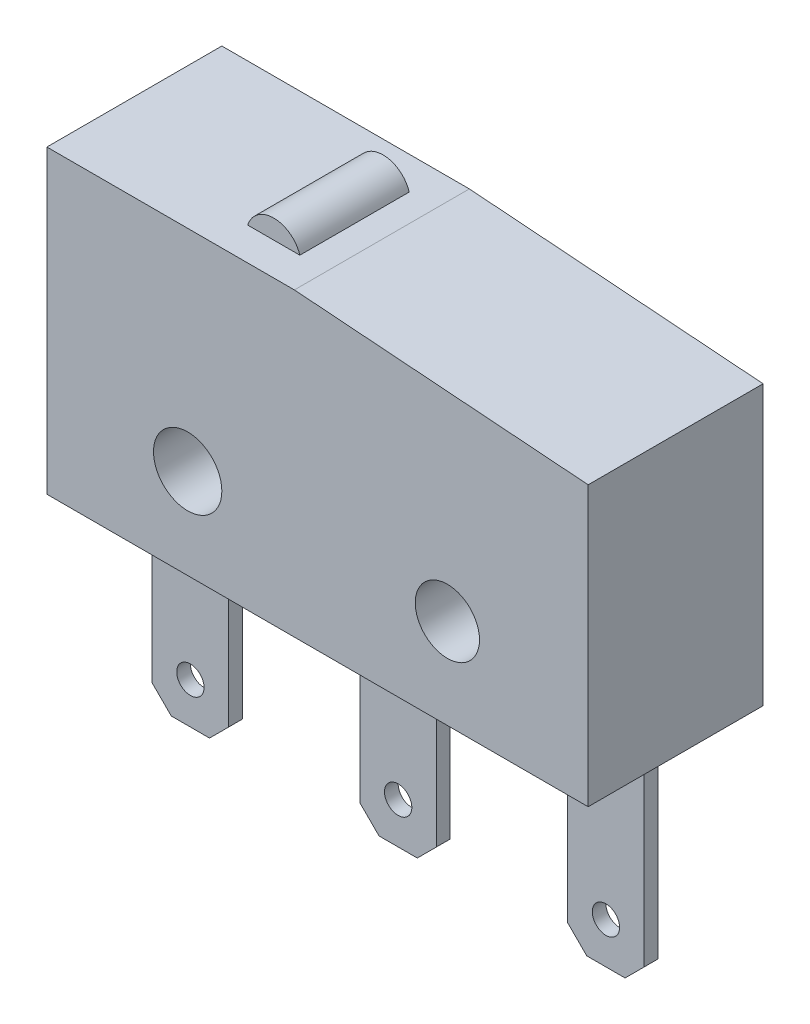
from build123d import *

# Parameters (mm, degrees)
SKETCH1_R           = 1.25
SKETCH1_R_2         = 1.175
BOSS_EXTRUDE1_DEPTH = 3.2
SKETCH2_R           = 0.5
BOSS_EXTRUDE2_DEPTH = 0.25
SKETCH3_W           = 2.907878402
SKETCH3_H           = 1.2
CUT_EXTRUDE1_DEPTH  = 1.7


with BuildPart() as part:
    # Sketch1 → Boss-Extrude1 (new body, symmetric)
    with BuildSketch(Plane.XY):
        with BuildLine():
            Line((-5.15, -3.3), (14.65, -3.3))
            Line((14.65, -3.3), (14.65, 6.9))
            Line((14.65, 6.9), (3.903939201, 7.7))
            Line((3.903939201, 7.7), (2.903939201, 7.7))
            ThreePointArc((2.903939201, 7.7), (1.95, 8.4), (0.996060799, 7.7))
            Line((0.996060799, 7.7), (-5.15, 7.7))
            Line((-5.15, 7.7), (-5.15, -3.3))
        make_face()
        Circle(SKETCH1_R, mode=Mode.SUBTRACT)
        with Locations((9.5, 0)):
            Circle(SKETCH1_R_2, mode=Mode.SUBTRACT)
    extrude(amount=BOSS_EXTRUDE1_DEPTH, both=True)

    # Sketch2 → Boss-Extrude2 (add, symmetric)
    with BuildSketch(Plane.XY):
        Polygon((-4.25, -3.3), (-1.45, -3.3), (-1.45, -10.3), (-2.15, -11), (-3.55, -11), (-4.25, -10.3), align=None)
        with Locations((-2.85, -9.5)):
            Circle(SKETCH2_R, mode=Mode.SUBTRACT)
        Polygon((3.35, -3.3), (6.15, -3.3), (6.15, -10.3), (5.45, -11), (4.05, -11), (3.35, -10.3), align=None)
        with Locations((4.75, -9.5)):
            Circle(SKETCH2_R, mode=Mode.SUBTRACT)
        Polygon((10.95, -3.3), (13.75, -3.3), (13.75, -10.3), (13.05, -11), (11.65, -11), (10.95, -10.3), align=None)
        with Locations((12.35, -9.5)):
            Circle(SKETCH2_R, mode=Mode.SUBTRACT)
    extrude(amount=BOSS_EXTRUDE2_DEPTH, both=True)

    # Sketch3 → Cut-Extrude1 (cut, through all)
    with BuildSketch(Plane(origin=(0, 7.7, 0), x_dir=(1, 0, 0), z_dir=(0, 1, 0))):
        with Locations((2.45, 2.6)):
            Rectangle(SKETCH3_W, SKETCH3_H)
        with Locations((2.45, -2.6)):
            Rectangle(SKETCH3_W, SKETCH3_H)
    extrude(amount=CUT_EXTRUDE1_DEPTH, mode=Mode.SUBTRACT)


solid = part.part
